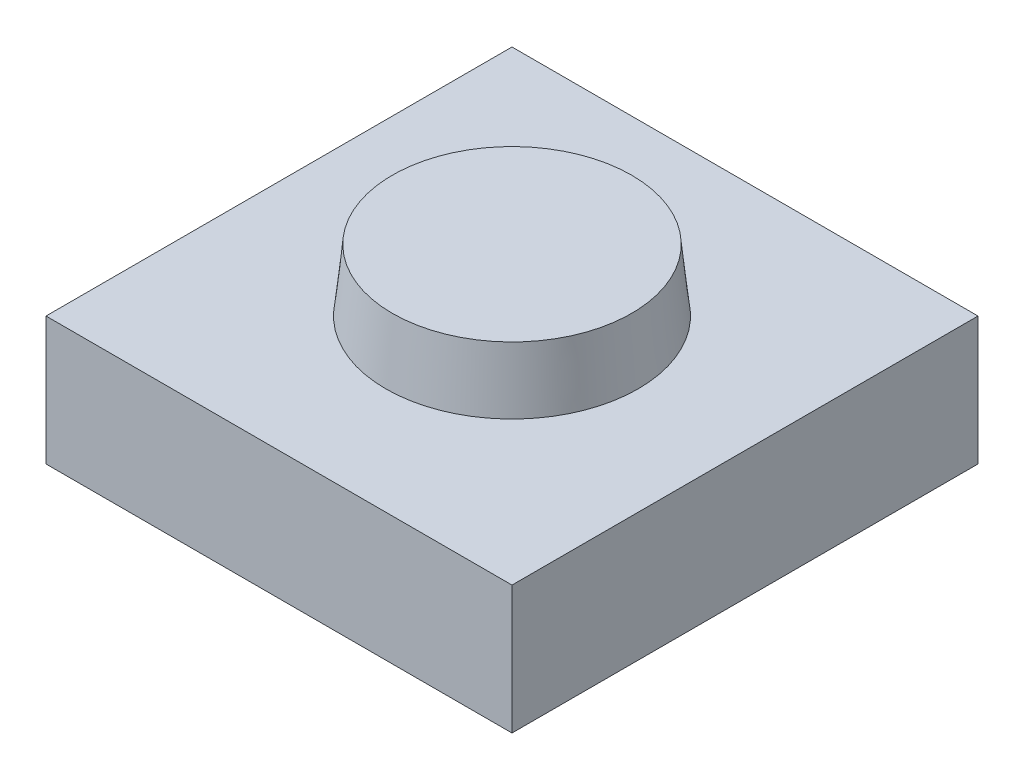
from build123d import *

# Parameters (mm, degrees)
SKETCH1_W           = 12
SKETCH1_H           = 12
BOSS_EXTRUDE1_DEPTH = 3.3
SKETCH2_R           = 3.25
BOSS_EXTRUDE2_DEPTH = 1.6
BOSS_EXTRUDE2_TAPER = 6


with BuildPart() as part:
    # Sketch1 → Boss-Extrude1 (new body)
    with BuildSketch(Plane(origin=(0, 0, 0), x_dir=(1, 0, 0), z_dir=(0, 1, 0))):
        Rectangle(SKETCH1_W, SKETCH1_H)
    extrude(amount=BOSS_EXTRUDE1_DEPTH)

    # Sketch2 → Boss-Extrude2 (add)
    with BuildSketch(Plane(origin=(0, 3.3, 0), x_dir=(1, 0, 0), z_dir=(0, 1, 0))):
        Circle(SKETCH2_R)
    extrude(amount=BOSS_EXTRUDE2_DEPTH, taper=BOSS_EXTRUDE2_TAPER)


solid = part.part
